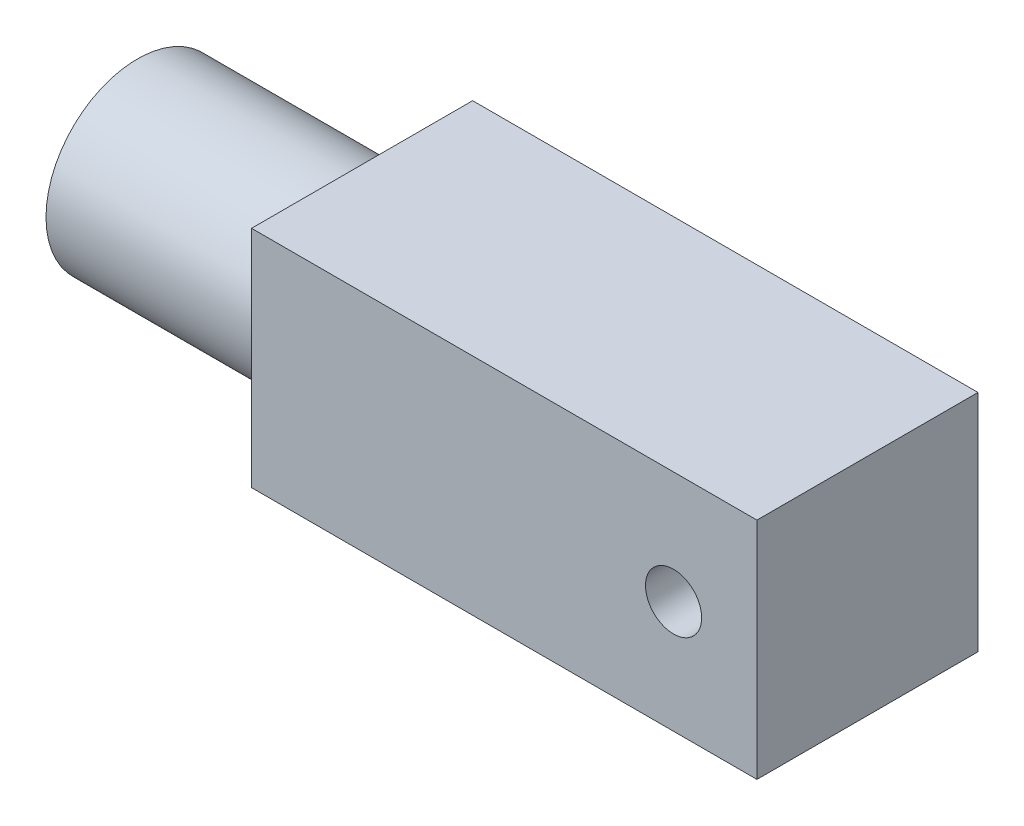
from build123d import *

# Parameters (mm, degrees)
SKETCH1_W           = 45.72
SKETCH1_H           = 20
BOSS_EXTRUDE1_DEPTH = 20.32
SKETCH2_R           = 8.276149927
BOSS_EXTRUDE2_DEPTH = 20.32
SKETCH4_R           = 2.54
CUT_EXTRUDE1_DEPTH  = 19.05


with BuildPart() as part:
    # Sketch1 → Boss-Extrude1 (new body)
    with BuildSketch(Plane(origin=(0, 0, 1.285201824), x_dir=(1, 0, 0), z_dir=(0, 1, 0))):
        with Locations((-5.388735632, 10)):
            Rectangle(SKETCH1_W, SKETCH1_H)
    extrude(amount=BOSS_EXTRUDE1_DEPTH)

    # Sketch2 → Boss-Extrude2 (add)
    with BuildSketch(Plane(origin=(-28.248735632, 0, 1.285201824), x_dir=(0, 0, 1), z_dir=(-1, 0, 0))):
        with Locations((-10, 10.16)):
            Circle(SKETCH2_R)
    extrude(amount=BOSS_EXTRUDE2_DEPTH)

    # Sketch4 → Cut-Extrude1 (cut)
    with BuildSketch(Plane.XY.offset(1.285201824)):
        with Locations((9.928717344, 10.16)):
            Circle(SKETCH4_R)
    extrude(amount=-CUT_EXTRUDE1_DEPTH, mode=Mode.SUBTRACT)


solid = part.part
